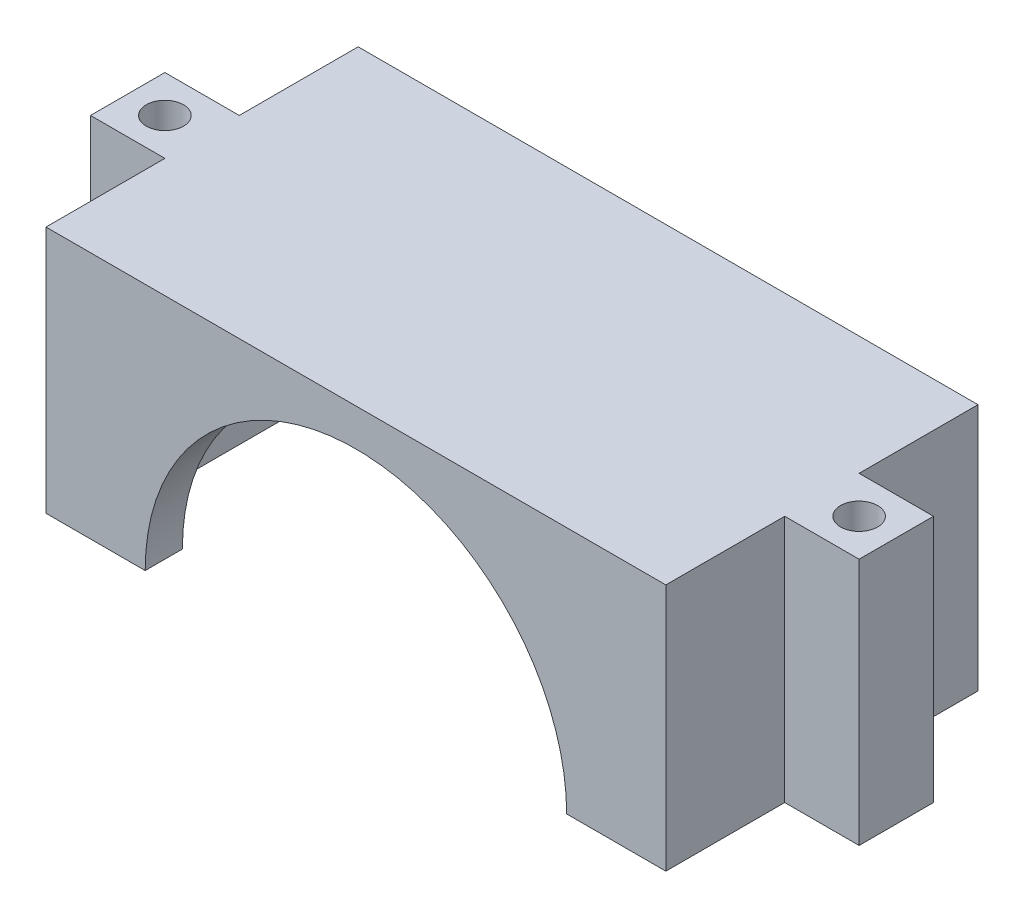
from build123d import *

# Parameters (mm, degrees)
SKETCH1_W           = 50
SKETCH1_H           = 25.18
BOSS_EXTRUDE1_DEPTH = 20
SKETCH6_W           = 44
SKETCH6_H           = 19.18
CUT_EXTRUDE4_DEPTH  = 17
CUT_EXTRUDE5_DEPTH  = 3
SKETCH8_W           = 10
SKETCH8_H           = 6
CUT_EXTRUDE6_DEPTH  = 17
SKETCH9_W           = 6
SKETCH9_H           = 6
SKETCH9_R           = 1.5
BOSS_EXTRUDE2_DEPTH = 20


with BuildPart() as part:
    # Sketch1 → Boss-Extrude1 (new body)
    with BuildSketch(Plane(origin=(0, 0, 0), x_dir=(1, 0, 0), z_dir=(0, 1, 0))):
        Rectangle(SKETCH1_W, SKETCH1_H)
    extrude(amount=BOSS_EXTRUDE1_DEPTH)

    # Sketch6 → Cut-Extrude4 (cut)
    with BuildSketch(Plane.XZ):
        Rectangle(SKETCH6_W, SKETCH6_H)
    extrude(amount=-CUT_EXTRUDE4_DEPTH, mode=Mode.SUBTRACT)

    # Sketch7 → Cut-Extrude5 (cut)
    with BuildSketch(Plane.XY.offset(12.59)):
        with BuildLine():
            Line((-17, 0), (17, 0))
            ThreePointArc((17, 0), (0, 17), (-17, 0))
        make_face()
    extrude(amount=-CUT_EXTRUDE5_DEPTH, mode=Mode.SUBTRACT)

    # Sketch8 → Cut-Extrude6 (cut)
    with BuildSketch(Plane(origin=(0, 0, -12.59), x_dir=(-1, 0, 0), z_dir=(0, 0, -1))):
        with Locations((-17, 3)):
            Rectangle(SKETCH8_W, SKETCH8_H)
    extrude(amount=-CUT_EXTRUDE6_DEPTH, mode=Mode.SUBTRACT)

    # Sketch9 → Boss-Extrude2 (add)
    with BuildSketch(Plane(origin=(0, 20, 0), x_dir=(1, 0, 0), z_dir=(0, 1, 0))):
        with Locations((28, 0)):
            Rectangle(SKETCH9_W, SKETCH9_H)
        with Locations((28, 0)):
            Circle(SKETCH9_R, mode=Mode.SUBTRACT)
        with Locations((-28, 0)):
            Rectangle(SKETCH9_W, SKETCH9_H)
        with Locations((-28, 0)):
            Circle(SKETCH9_R, mode=Mode.SUBTRACT)
    extrude(amount=-BOSS_EXTRUDE2_DEPTH)


solid = part.part
